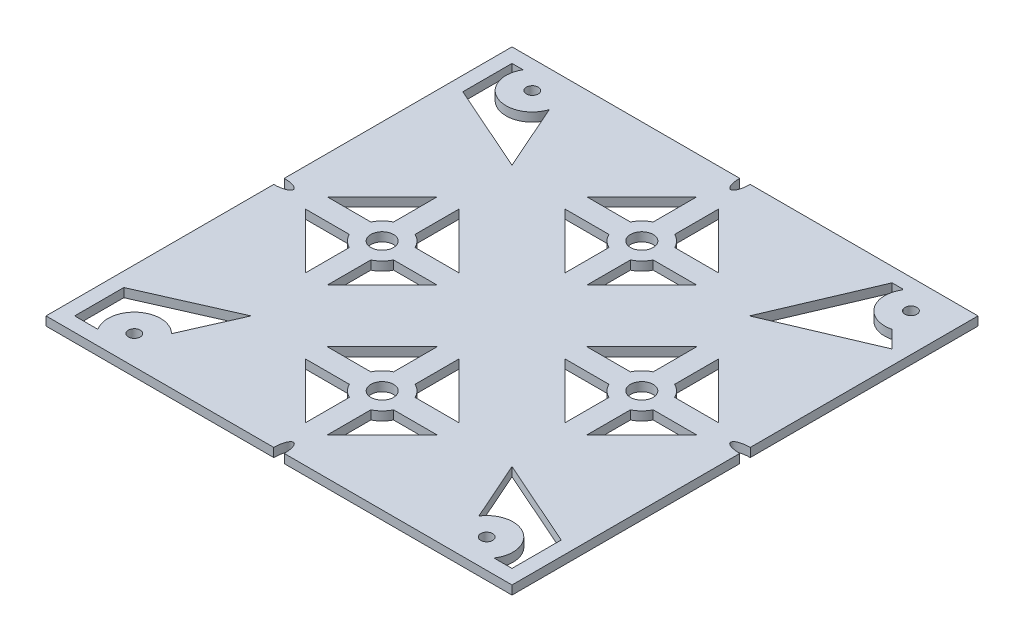
from build123d import *

# Parameters (mm, degrees)
SKETCH1_W           = 97.6
SKETCH1_H           = 97.6
BOSS_EXTRUDE1_DEPTH = 1.85
SKETCH3_R           = 1.25
CUT_EXTRUDE1_DEPTH  = 10
FILLET1_R           = 0.2
SKETCH5_R           = 2.375
CUT_EXTRUDE2_DEPTH  = 10


with BuildPart() as part:
    # Sketch1 → Boss-Extrude1 (new body)
    with BuildSketch(Plane(origin=(0, 0, 0), x_dir=(1, 0, 0), z_dir=(0, 1, 0))):
        with Locations((48.8, 48.8)):
            Rectangle(SKETCH1_W, SKETCH1_H)
    extrude(amount=BOSS_EXTRUDE1_DEPTH)

    # Sketch3 → Cut-Extrude1 (cut)
    with BuildSketch(Plane.XZ):
        with BuildLine():
            Line((3, -84.3), (3, -94.6))
            Line((3, -94.6), (5.316079849, -94.6))
            ThreePointArc((5.316079849, -94.6), (7.792729855, -86.784550719), (15.285000001, -90.113353923))
            Line((15.285000001, -90.113353923), (21.472818771, -76.127181229))
            Line((21.472818771, -76.127181229), (3, -84.3))
        make_face()
        with BuildLine():
            Line((3, -13.3), (21.472818771, -21.472818771))
            Line((21.472818771, -21.472818771), (16.360495139, -9.917560959))
            ThreePointArc((16.360495139, -9.917560959), (8.975209709, -10.313312378), (7.873156109, -3))
            Line((7.873156109, -3), (3, -3))
            Line((3, -3), (3, -13.3))
        make_face()
        with BuildLine():
            Line((94.6, -13.3), (94.6, -3))
            Line((94.6, -3), (90.826843891, -3))
            ThreePointArc((90.826843891, -3), (89.267333256, -10.648445392), (81.630186258, -9.034513526))
            Line((81.630186258, -9.034513526), (76.127181229, -21.472818771))
            Line((76.127181229, -21.472818771), (94.6, -13.3))
        make_face()
        with BuildLine():
            Line((91.027327292, -86.172672708), (94.6, -82.6))
            Line((94.6, -82.6), (73.674141566, -73.674141566))
            Line((73.674141566, -73.674141566), (82.6, -94.6))
            Line((82.6, -94.6), (85.116873323, -94.6))
            ThreePointArc((85.116873323, -94.6), (85.157069093, -88.341897208), (91.027327292, -86.172672708))
        make_face()
        with Locations((89.66, -91.5)):
            Circle(SKETCH3_R)
        with Locations((10.05, -91.8)):
            Circle(SKETCH3_R)
        with Locations((12.45, -6.05)):
            Circle(SKETCH3_R)
        with Locations((86.25, -6.05)):
            Circle(SKETCH3_R)
    extrude(amount=-CUT_EXTRUDE1_DEPTH, mode=Mode.SUBTRACT)

    # Fillet1
    fillet1_edges = [part.edges().sort_by_distance(p)[0] for p in [
        (85.116873323, 0.925, -94.6),
    ]]
    fillet(fillet1_edges, radius=FILLET1_R)

    # Sketch5 → Cut-Extrude2 (cut)
    with BuildSketch(Plane.XZ):
        with BuildLine():
            Line((51.05, -80.617052601), (51.05, -89.767052601))
            Line((51.05, -89.767052601), (62.582493929, -78.234558673))
            Line((62.582493929, -78.234558673), (53.432493929, -78.234558673))
            ThreePointArc((53.432493929, -78.234558673), (52.441599923, -79.626158596), (51.05, -80.617052601))
        make_face()
        with BuildLine():
            Line((46.55, -89.767052601), (46.55, -80.617052601))
            ThreePointArc((46.55, -80.617052601), (45.158400077, -79.626158596), (44.167506071, -78.234558673))
            Line((44.167506071, -78.234558673), (35.017506071, -78.234558673))
            Line((35.017506071, -78.234558673), (46.55, -89.767052601))
        make_face()
        with Locations((48.8, -75.984558673)):
            Circle(SKETCH5_R)
        with BuildLine():
            ThreePointArc((51.05, -71.352064744), (52.441599923, -72.34295875), (53.432493929, -73.734558673))
            Line((53.432493929, -73.734558673), (62.582493929, -73.734558673))
            Line((62.582493929, -73.734558673), (51.05, -62.202064744))
            Line((51.05, -62.202064744), (51.05, -71.352064744))
        make_face()
        with BuildLine():
            Line((35.017506071, -73.734558673), (44.167506071, -73.734558673))
            ThreePointArc((44.167506071, -73.734558673), (45.158400077, -72.34295875), (46.55, -71.352064744))
            Line((46.55, -71.352064744), (46.55, -62.202064744))
            Line((46.55, -62.202064744), (35.017506071, -73.734558673))
        make_face()
        with BuildLine():
            Line((19.365441327, -62.582493929), (19.365441327, -53.432493929))
            ThreePointArc((19.365441327, -53.432493929), (17.973841404, -52.441599923), (16.982947399, -51.05))
            Line((16.982947399, -51.05), (7.832947399, -51.05))
            Line((7.832947399, -51.05), (19.365441327, -62.582493929))
        make_face()
        with BuildLine():
            Line((23.865441327, -62.582493929), (35.397935256, -51.05))
            Line((35.397935256, -51.05), (26.247935256, -51.05))
            ThreePointArc((26.247935256, -51.05), (25.25704125, -52.441599923), (23.865441327, -53.432493929))
            Line((23.865441327, -53.432493929), (23.865441327, -62.582493929))
        make_face()
        with BuildLine():
            ThreePointArc((23.865441327, -44.167506071), (25.25704125, -45.158400077), (26.247935256, -46.55))
            Line((26.247935256, -46.55), (35.397935256, -46.55))
            Line((35.397935256, -46.55), (23.865441327, -35.017506071))
            Line((23.865441327, -35.017506071), (23.865441327, -44.167506071))
        make_face()
        with BuildLine():
            Line((7.832947399, -46.55), (16.982947399, -46.55))
            ThreePointArc((16.982947399, -46.55), (17.973841404, -45.158400077), (19.365441327, -44.167506071))
            Line((19.365441327, -44.167506071), (19.365441327, -35.017506071))
            Line((19.365441327, -35.017506071), (7.832947399, -46.55))
        make_face()
        with Locations((21.615441327, -48.8)):
            Circle(SKETCH5_R)
        with Locations((75.984558673, -48.8)):
            Circle(SKETCH5_R)
        with BuildLine():
            ThreePointArc((80.617052601, -51.05), (79.626158596, -52.441599923), (78.234558673, -53.432493929))
            Line((78.234558673, -53.432493929), (78.234558673, -62.582493929))
            Line((78.234558673, -62.582493929), (89.767052601, -51.05))
            Line((89.767052601, -51.05), (80.617052601, -51.05))
        make_face()
        with BuildLine():
            ThreePointArc((73.734558673, -53.432493929), (72.34295875, -52.441599923), (71.352064744, -51.05))
            Line((71.352064744, -51.05), (62.202064744, -51.05))
            Line((62.202064744, -51.05), (73.734558673, -62.582493929))
            Line((73.734558673, -62.582493929), (73.734558673, -53.432493929))
        make_face()
        with BuildLine():
            Line((73.734558673, -35.017506071), (62.202064744, -46.55))
            Line((62.202064744, -46.55), (71.352064744, -46.55))
            ThreePointArc((71.352064744, -46.55), (72.34295875, -45.158400077), (73.734558673, -44.167506071))
            Line((73.734558673, -44.167506071), (73.734558673, -35.017506071))
        make_face()
        with BuildLine():
            Line((78.234558673, -35.017506071), (78.234558673, -44.167506071))
            ThreePointArc((78.234558673, -44.167506071), (79.626158596, -45.158400077), (80.617052601, -46.55))
            Line((80.617052601, -46.55), (89.767052601, -46.55))
            Line((89.767052601, -46.55), (78.234558673, -35.017506071))
        make_face()
        with BuildLine():
            Line((46.55, -16.982947399), (46.55, -7.832947399))
            Line((46.55, -7.832947399), (35.017506071, -19.365441327))
            Line((35.017506071, -19.365441327), (44.167506071, -19.365441327))
            ThreePointArc((44.167506071, -19.365441327), (45.158400077, -17.973841404), (46.55, -16.982947399))
        make_face()
        with BuildLine():
            Line((51.05, -7.832947399), (51.05, -16.982947399))
            ThreePointArc((51.05, -16.982947399), (52.441599923, -17.973841404), (53.432493929, -19.365441327))
            Line((53.432493929, -19.365441327), (62.582493929, -19.365441327))
            Line((62.582493929, -19.365441327), (51.05, -7.832947399))
        make_face()
        with BuildLine():
            Line((62.582493929, -23.865441327), (53.432493929, -23.865441327))
            ThreePointArc((53.432493929, -23.865441327), (52.441599923, -25.25704125), (51.05, -26.247935256))
            Line((51.05, -26.247935256), (51.05, -35.397935256))
            Line((51.05, -35.397935256), (62.582493929, -23.865441327))
        make_face()
        with BuildLine():
            ThreePointArc((46.55, -26.247935256), (45.158400077, -25.25704125), (44.167506071, -23.865441327))
            Line((44.167506071, -23.865441327), (35.017506071, -23.865441327))
            Line((35.017506071, -23.865441327), (46.55, -35.397935256))
            Line((46.55, -35.397935256), (46.55, -26.247935256))
        make_face()
        with BuildLine():
            add(Edge.make_bspline(
                [(47.7, -97.6), (47.7, -100.595404627), (48.8, -100.595404627), (49.9, -100.595404627), (49.9, -97.6)],
                knots=[1.570796327, 1.570796327, 1.570796327, 3.141592654, 3.141592654, 4.71238898, 4.71238898, 4.71238898], degree=2, weights=[1, 0.707106781, 1, 0.707106781, 1]))
            Line((49.9, -97.6), (47.7, -97.6))
        make_face()
        with BuildLine():
            Line((47.7, -97.6), (49.9, -97.6))
            add(Edge.make_bspline(
                [(49.9, -97.6), (49.9, -94.604595373), (48.8, -94.604595373)],
                knots=[4.71238898, 4.71238898, 4.71238898, 6.283185307, 6.283185307, 6.283185307], degree=2, weights=[1, 0.707106781, 1]))
            add(Edge.make_bspline(
                [(48.8, -94.604595373), (47.7, -94.604595373), (47.7, -97.6)],
                knots=[0, 0, 0, 1.570796327, 1.570796327, 1.570796327], degree=2, weights=[1, 0.707106781, 1]))
        make_face()
        with BuildLine():
            add(Edge.make_bspline(
                [(48.8, -3), (49.9, -3), (49.9, 0)],
                knots=[0, 0, 0, 1.570796327, 1.570796327, 1.570796327], degree=2, weights=[1, 0.707106781, 1]))
            Line((49.9, 0), (48.8, 0))
            Line((48.8, 0), (47.7, 0))
            add(Edge.make_bspline(
                [(47.7, 0), (47.7, -3), (48.8, -3)],
                knots=[4.71238898, 4.71238898, 4.71238898, 6.283185307, 6.283185307, 6.283185307], degree=2, weights=[1, 0.707106781, 1]))
        make_face()
        with BuildLine():
            Line((48.8, 0), (49.9, 0))
            add(Edge.make_bspline(
                [(49.9, 0), (49.9, 3), (48.8, 3), (47.7, 3), (47.7, 0)],
                knots=[1.570796327, 1.570796327, 1.570796327, 3.141592654, 3.141592654, 4.71238898, 4.71238898, 4.71238898], degree=2, weights=[1, 0.707106781, 1, 0.707106781, 1]))
            Line((47.7, 0), (48.8, 0))
        make_face()
        with BuildLine():
            add(Edge.make_bspline(
                [(94.596161078, -48.8), (94.596161078, -49.9), (97.6, -49.9)],
                knots=[0, 0, 0, 1.570796327, 1.570796327, 1.570796327], degree=2, weights=[1, 0.707106781, 1]))
            Line((97.6, -49.9), (97.6, -48.8))
            Line((97.6, -48.8), (97.6, -47.7))
            add(Edge.make_bspline(
                [(97.6, -47.7), (94.596161078, -47.7), (94.596161078, -48.8)],
                knots=[4.71238898, 4.71238898, 4.71238898, 6.283185307, 6.283185307, 6.283185307], degree=2, weights=[1, 0.707106781, 1]))
        make_face()
        with BuildLine():
            Line((97.6, -48.8), (97.6, -49.9))
            add(Edge.make_bspline(
                [(97.6, -49.9), (100.603838922, -49.9), (100.603838922, -48.8), (100.603838922, -47.7), (97.6, -47.7)],
                knots=[1.570796327, 1.570796327, 1.570796327, 3.141592654, 3.141592654, 4.71238898, 4.71238898, 4.71238898], degree=2, weights=[1, 0.707106781, 1, 0.707106781, 1]))
            Line((97.6, -47.7), (97.6, -48.8))
        make_face()
        with BuildLine():
            add(Edge.make_bspline(
                [(0, -47.7), (-3, -47.7), (-3, -48.8), (-3, -49.9), (0, -49.9)],
                knots=[1.570796327, 1.570796327, 1.570796327, 3.141592654, 3.141592654, 4.71238898, 4.71238898, 4.71238898], degree=2, weights=[1, 0.707106781, 1, 0.707106781, 1]))
            Line((0, -49.9), (0, -48.8))
            Line((0, -48.8), (0, -47.7))
        make_face()
        with BuildLine():
            Line((0, -48.8), (0, -49.9))
            add(Edge.make_bspline(
                [(0, -49.9), (3, -49.9), (3, -48.8)],
                knots=[4.71238898, 4.71238898, 4.71238898, 6.283185307, 6.283185307, 6.283185307], degree=2, weights=[1, 0.707106781, 1]))
            add(Edge.make_bspline(
                [(3, -48.8), (3, -47.7), (0, -47.7)],
                knots=[0, 0, 0, 1.570796327, 1.570796327, 1.570796327], degree=2, weights=[1, 0.707106781, 1]))
            Line((0, -47.7), (0, -48.8))
        make_face()
        with Locations((48.8, -21.615441327)):
            Circle(SKETCH5_R)
    extrude(amount=-CUT_EXTRUDE2_DEPTH, mode=Mode.SUBTRACT)


solid = part.part
